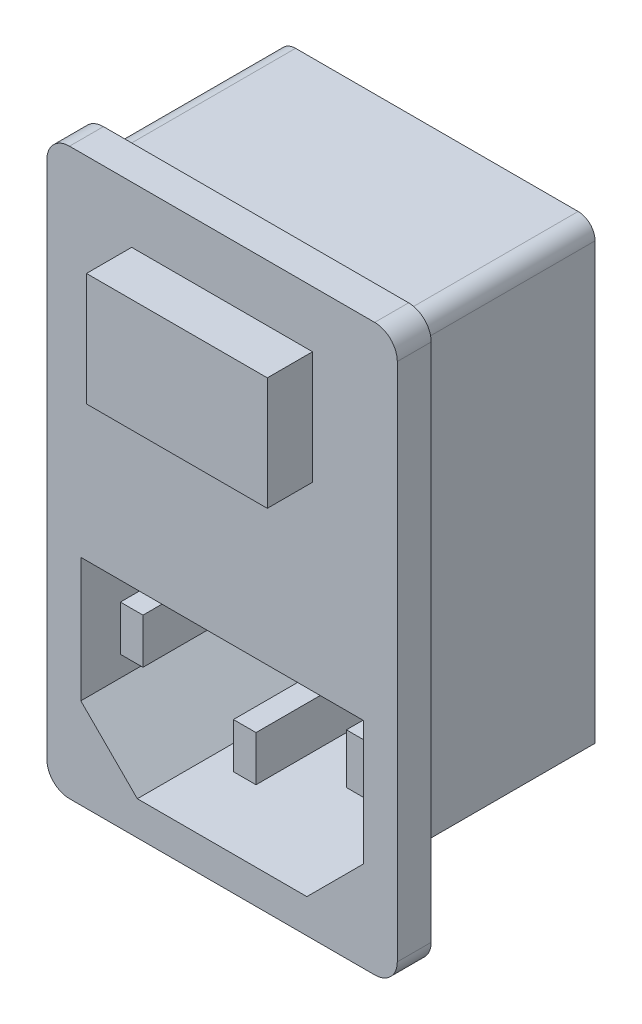
from build123d import *

# Parameters (mm, degrees)
BOSS_EXTRUDE1_DEPTH = 3
BOSS_EXTRUDE2_DEPTH = 16
SKETCH3_W           = 16
SKETCH3_H           = 10
BOSS_EXTRUDE3_DEPTH = 4
CUT_EXTRUDE1_DEPTH  = 17
SKETCH5_W           = 2
SKETCH5_H           = 4
SKETCH5_H_2         = 4.422760465
BOSS_EXTRUDE4_DEPTH = 15


with BuildPart() as part:
    # Sketch1 → Boss-Extrude1 (new body)
    with BuildSketch(Plane.XY):
        with BuildLine():
            Line((-13.5, 25), (13.5, 25))
            ThreePointArc((13.5, 25), (14.914213562, 24.414213562), (15.5, 23))
            Line((15.5, 23), (15.5, -23))
            ThreePointArc((15.5, -23), (14.914213562, -24.414213562), (13.5, -25))
            Line((13.5, -25), (-13.5, -25))
            ThreePointArc((-13.5, -25), (-14.914213562, -24.414213562), (-15.5, -23))
            Line((-15.5, -23), (-15.5, 23))
            ThreePointArc((-15.5, 23), (-14.914213562, 24.414213562), (-13.5, 25))
        make_face()
    extrude(amount=BOSS_EXTRUDE1_DEPTH)

    # Sketch2 → Boss-Extrude2 (add)
    with BuildSketch(Plane(origin=(0, 0, 0), x_dir=(-1, 0, 0), z_dir=(0, 0, -1))):
        with BuildLine():
            Line((-12.5, 23.5), (12.5, 23.5))
            ThreePointArc((12.5, 23.5), (13.560660172, 23.060660172), (14, 22))
            Line((14, 22), (14, -16.5))
            Line((14, -16.5), (7, -23.5))
            Line((7, -23.5), (-7, -23.5))
            Line((-7, -23.5), (-14, -16.5))
            Line((-14, -16.5), (-14, 22))
            ThreePointArc((-14, 22), (-13.560660172, 23.060660172), (-12.5, 23.5))
        make_face()
    extrude(amount=BOSS_EXTRUDE2_DEPTH)

    # Sketch3 → Boss-Extrude3 (add)
    with BuildSketch(Plane.XY.offset(3)):
        with Locations((0, 15)):
            Rectangle(SKETCH3_W, SKETCH3_H)
    extrude(amount=BOSS_EXTRUDE3_DEPTH)

    # Sketch4 → Cut-Extrude1 (cut)
    with BuildSketch(Plane.XY.offset(3)):
        Polygon((-12.5, -17), (-7.5, -22), (7.5, -22), (12.5, -17), (12.5, -6), (-12.5, -6), align=None)
    extrude(amount=-CUT_EXTRUDE1_DEPTH, mode=Mode.SUBTRACT)

    # Sketch5 → Boss-Extrude4 (add)
    with BuildSketch(Plane.XY.offset(-14)):
        with Locations((0, -15.680542245)):
            Rectangle(SKETCH5_W, SKETCH5_H)
        with Locations((-10, -11.680542245)):
            Rectangle(SKETCH5_W, SKETCH5_H)
        with Locations((10, -11.680542244)):
            Rectangle(SKETCH5_W, SKETCH5_H_2)
    extrude(amount=BOSS_EXTRUDE4_DEPTH)


solid = part.part
